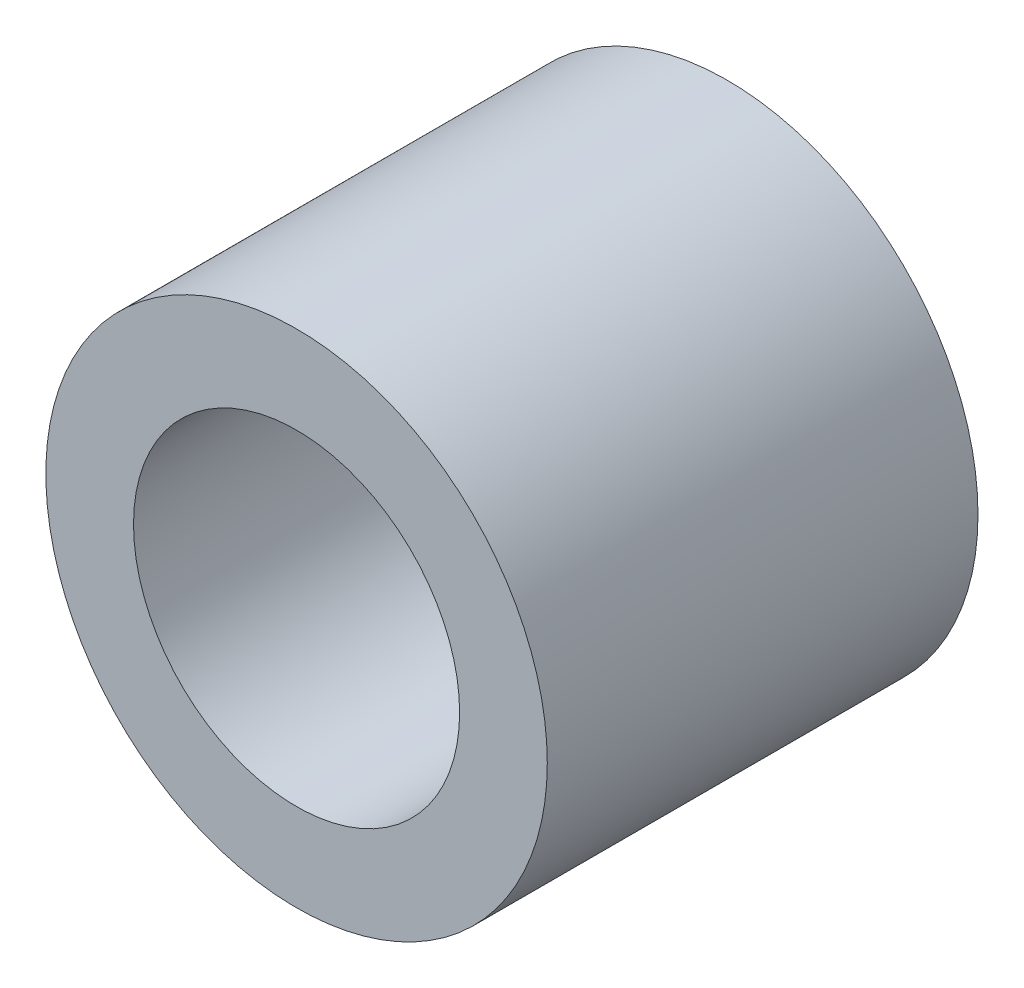
from build123d import *

# Parameters (mm, degrees)
SKETCH1_R            = 4.075
BOSS_EXTRUDE1_DEPTH  = 7
M5_CLEARANCE_HOLE1_D = 5.3


with BuildPart() as part:
    # Sketch1 → Boss-Extrude1 (new body)
    with BuildSketch(Plane.XY):
        Circle(SKETCH1_R)
    extrude(amount=BOSS_EXTRUDE1_DEPTH)

    # M5 Clearance Hole1 (through all)
    with Locations(Plane.XY.offset(7)):
        with Locations((0, 0)):
            Hole(M5_CLEARANCE_HOLE1_D / 2)


solid = part.part
